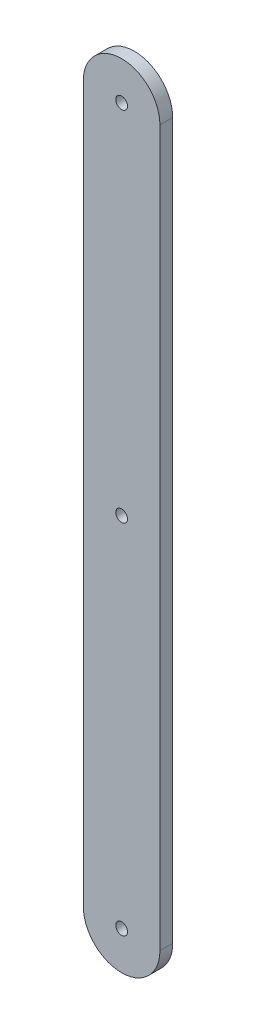
from build123d import *

# Parameters (mm, degrees)
SKETCH1_R           = 1.4605
BOSS_EXTRUDE1_DEPTH = 3.175
SKETCH2_R           = 1.4605
CUT_EXTRUDE1_DEPTH  = 3.175


with BuildPart() as part:
    # Sketch1 → Boss-Extrude1 (new body)
    with BuildSketch(Plane.XY):
        with BuildLine():
            Line((-19.353012887, 0), (-19.353012887, 177.8))
            ThreePointArc((-19.353012887, 177.8), (-9.828012887, 187.325), (-0.303012887, 177.8))
            Line((-0.303012887, 177.8), (-0.303012887, 0))
            ThreePointArc((-0.303012887, 0), (-9.828012887, -9.525), (-19.353012887, 0))
        make_face()
        with Locations((-9.828012887, 0)):
            Circle(SKETCH1_R, mode=Mode.SUBTRACT)
        with Locations((-9.828012887, 177.8)):
            Circle(SKETCH1_R, mode=Mode.SUBTRACT)
    extrude(amount=BOSS_EXTRUDE1_DEPTH)

    # Sketch2 → Cut-Extrude1 (cut)
    with BuildSketch(Plane(origin=(0, 0, 0), x_dir=(-1, 0, 0), z_dir=(0, 0, -1))):
        with Locations((9.828012887, 88.9)):
            Circle(SKETCH2_R)
    extrude(amount=-CUT_EXTRUDE1_DEPTH, mode=Mode.SUBTRACT)


solid = part.part
